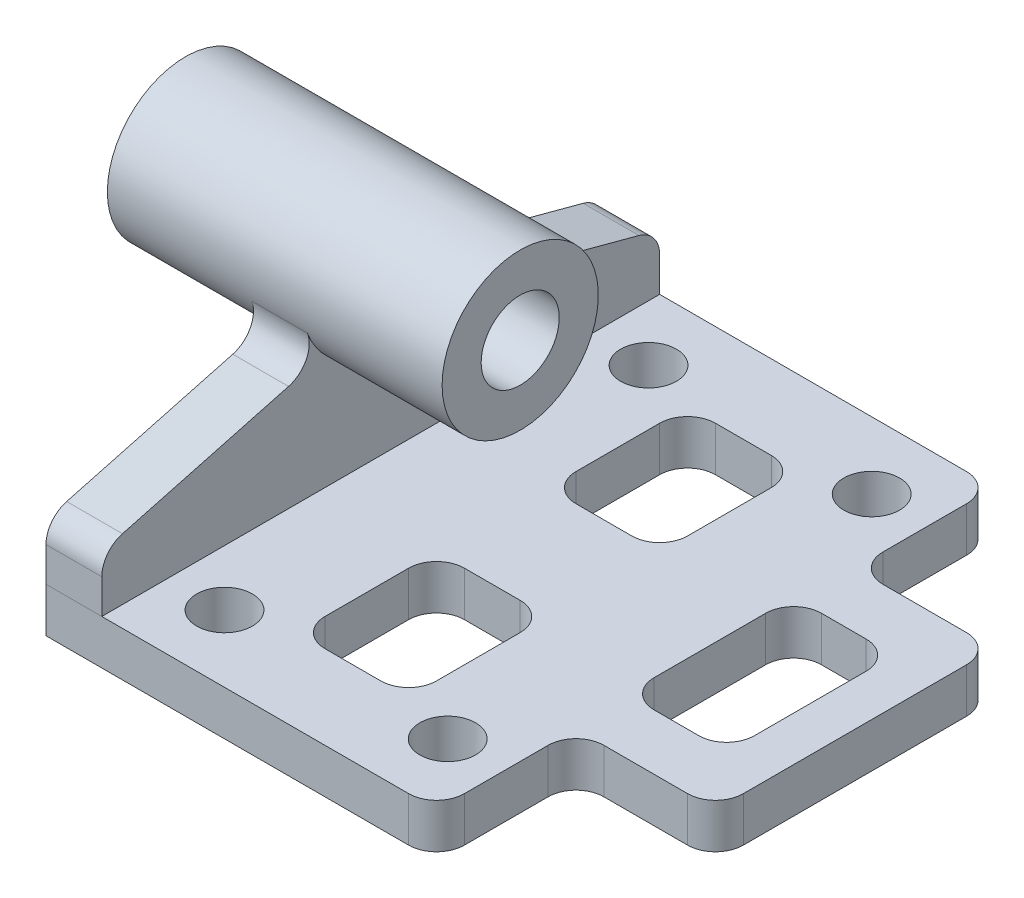
from build123d import *

# Parameters (mm, degrees)
SKETCH1_R                = 5
SKETCH1_W                = 20
SKETCH1_H                = 25
SKETCH1_W_2              = 18
SKETCH1_H_2              = 30
BOSS_EXTRUDE1_DEPTH      = 8
FILLET1_R                = 5
BOSS_EXTRUDE2_DEPTH      = 10
BOSS_EXTRUDE3_DEPTH      = 25
BOSS_EXTRUDE3_DEPTH_BACK = 35
SKETCH3_3_R              = 14
SKETCH3_3_R_2            = 7
FILLET2_R                = 5


with BuildPart() as part:
    # Sketch1 → Boss-Extrude1 (new body)
    with BuildSketch(Plane(origin=(0, 0, 0), x_dir=(1, 0, 0), z_dir=(0, 1, 0))):
        Polygon((0, 100), (70, 100), (70, 75), (95, 75), (95, 25), (70, 25), (70, 0), (0, 0), align=None)
        with Locations((60, 12)):
            Circle(SKETCH1_R, mode=Mode.SUBTRACT)
        with Locations((20, 12)):
            Circle(SKETCH1_R, mode=Mode.SUBTRACT)
        with Locations((20, 88)):
            Circle(SKETCH1_R, mode=Mode.SUBTRACT)
        with Locations((60, 88)):
            Circle(SKETCH1_R, mode=Mode.SUBTRACT)
        with Locations((40, 72.5)):
            Rectangle(SKETCH1_W, SKETCH1_H, mode=Mode.SUBTRACT)
        with Locations((40, 27.5)):
            Rectangle(SKETCH1_W, SKETCH1_H, mode=Mode.SUBTRACT)
        with Locations((78, 50)):
            Rectangle(SKETCH1_W_2, SKETCH1_H_2, mode=Mode.SUBTRACT)
    extrude(amount=BOSS_EXTRUDE1_DEPTH)

    # Fillet1
    fillet1_edges = [part.edges().sort_by_distance(p)[0] for p in [
        (70, 4, -25),
        (70, 4, 0),
        (95, 4, -25),
        (95, 4, -75),
        (70, 4, -100),
        (70, 4, -75),
        (87, 4, -65),
        (69, 4, -65),
        (87, 4, -35),
        (69, 4, -35),
        (50, 4, -15),
        (50, 4, -40),
        (30, 4, -40),
        (30, 4, -15),
        (30, 4, -60),
        (50, 4, -85),
        (50, 4, -60),
        (30, 4, -85),
    ]]
    fillet(fillet1_edges, radius=FILLET1_R)


with BuildPart() as body_2:
    # Sketch3 → Boss-Extrude2 (new body)
    with BuildSketch(Plane.ZY):
        with BuildLine():
            Line((-100, 18), (-100, 0))
            Line((-100, 0), (0, 0))
            Line((0, 0), (0, 18))
            Line((0, 18), (-39.908743007, 28.69351546))
            ThreePointArc((-39.908743007, 28.69351546), (-50, 24.397459622), (-60.091256993, 28.69351546))
            Line((-60.091256993, 28.69351546), (-100, 18))
        make_face()
    extrude(amount=-BOSS_EXTRUDE2_DEPTH)

    # Sketch3_3 → Boss-Extrude3 (add, two sides: drawn at the far end of the back side and taken through both)
    with BuildSketch(Plane.ZY.offset(-BOSS_EXTRUDE3_DEPTH_BACK)):
        with Locations((-50, 38.397459622)):
            Circle(SKETCH3_3_R)
        with Locations((-50, 38.397459622)):
            Circle(SKETCH3_3_R_2, mode=Mode.SUBTRACT)
    extrude(amount=BOSS_EXTRUDE3_DEPTH + BOSS_EXTRUDE3_DEPTH_BACK)

    # Fillet2
    fillet2_edges = [body_2.edges().sort_by_distance(p)[0] for p in [
        (5, 18, -100),
        (5, 18, 0),
        (5, 28.69351546, -60.091256993),
        (5, 28.69351546, -39.908743007),
    ]]
    fillet(fillet2_edges, radius=FILLET2_R)


solid = Compound([part.part, body_2.part])
